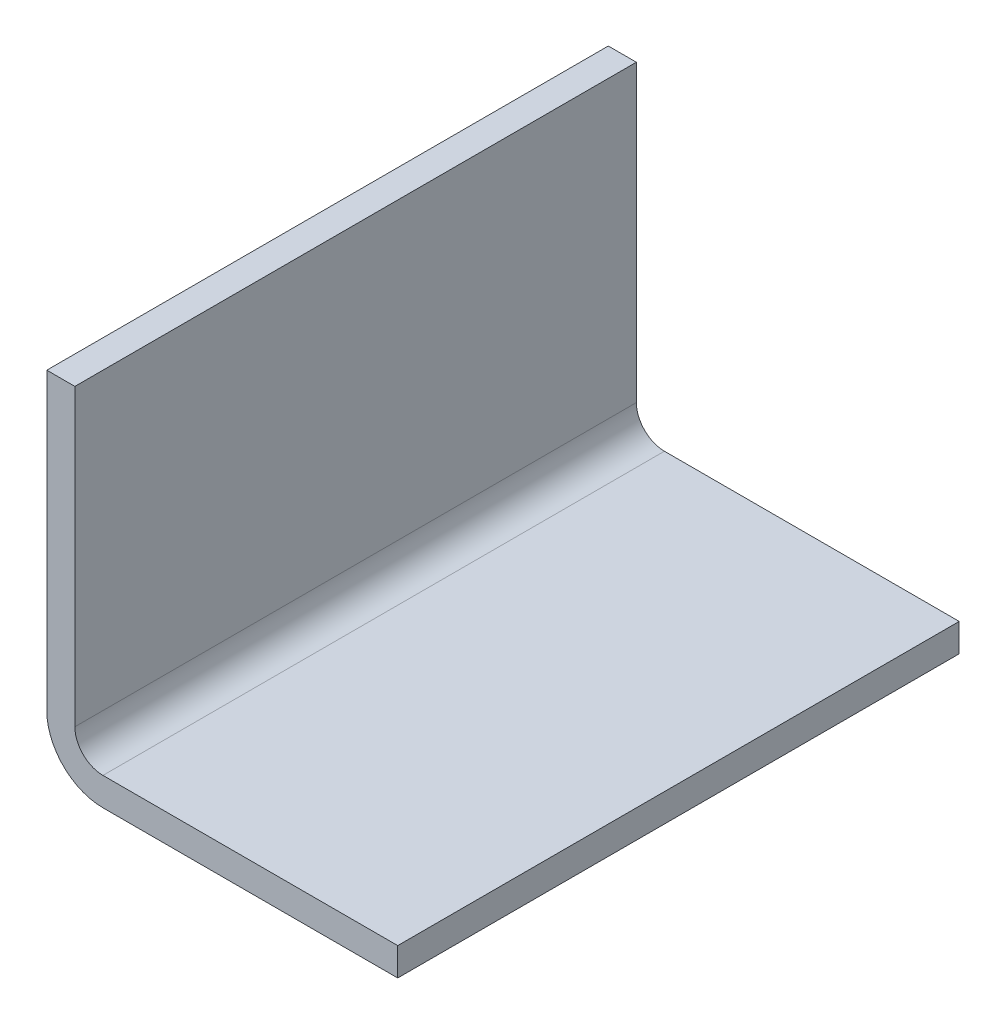
from build123d import *

# Parameters (mm, degrees)
BOSS_EXTRUDE1_DEPTH = 20


with BuildPart() as part:
    # Sketch1 → Boss-Extrude1 (new body, symmetric)
    with BuildSketch(Plane.XY):
        with BuildLine():
            Line((0, 4), (0, 25))
            Line((0, 25), (2, 25))
            Line((2, 25), (2, 4))
            ThreePointArc((2, 4), (2.585786438, 2.585786438), (4, 2))
            Line((4, 2), (25, 2))
            Line((25, 2), (25, 0))
            Line((25, 0), (4, 0))
            ThreePointArc((4, 0), (1.171572875, 1.171572875), (0, 4))
        make_face()
    extrude(amount=BOSS_EXTRUDE1_DEPTH, both=True)


solid = part.part
